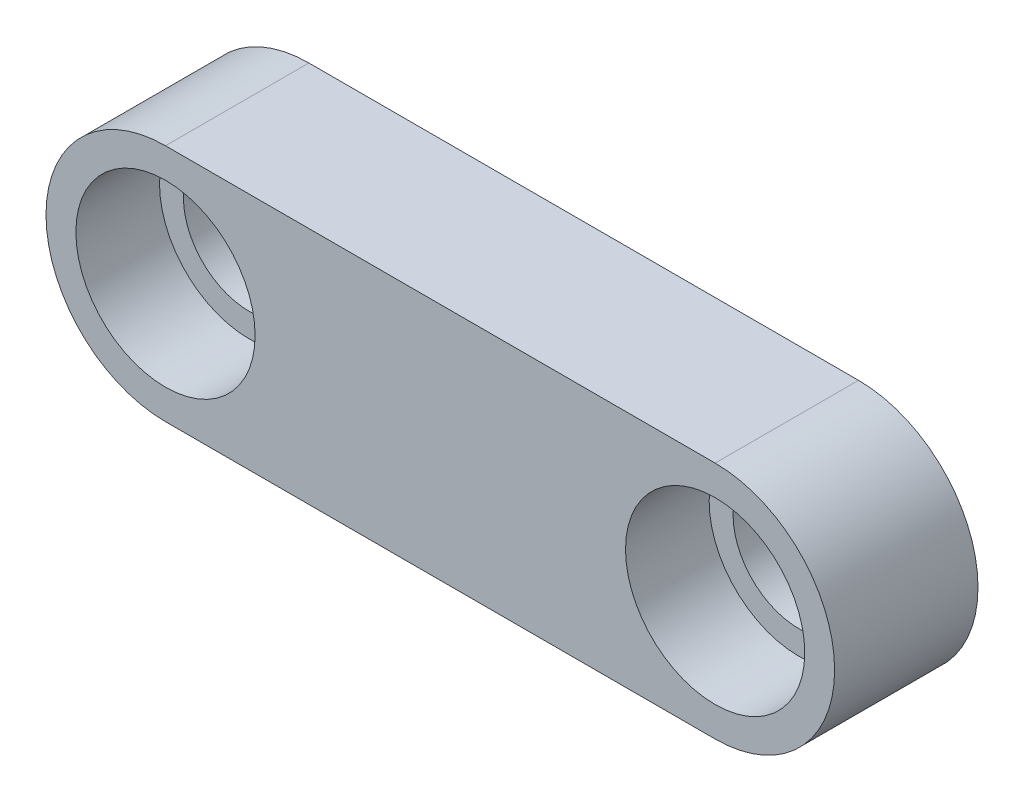
from build123d import *

# Parameters (mm, degrees)
EXTRUDE_1_DEPTH = 6


with BuildPart() as part:
    # 草图1 → 凸台-拉伸1 (new body)
    with BuildSketch(Plane.XY):
        with BuildLine():
            Line((0, 5), (23, 5))
            ThreePointArc((23, 5), (28, 0), (23, -5))
            Line((23, -5), (0, -5))
            ThreePointArc((0, -5), (-5, 0), (0, 5))
        make_face()
    extrude(amount=EXTRUDE_1_DEPTH)

    # 草图2 → 切除-旋转1 (revolve, cut)
    with BuildSketch(Plane(origin=(0, 0, 0), x_dir=(1, 0, 0), z_dir=(0, 1, 0))):
        Polygon((0, -6), (-3.75, -6), (-3.75, -2.5), (-2.75, -2.5), (-2.75, 0), (0, 0), align=None)
    revolve(axis=Axis((0, 0, 0), (0, 0, 1)), mode=Mode.SUBTRACT)

    # 草图3 → 切除-旋转2 (revolve, cut)
    with BuildSketch(Plane(origin=(0, 0, 0), x_dir=(1, 0, 0), z_dir=(0, 1, 0))):
        Polygon((23, -6), (19.25, -6), (19.25, -2.5), (20.25, -2.5), (20.25, 0), (23, 0), align=None)
    revolve(axis=Axis((23, 0, 0), (0, 0, 1)), mode=Mode.SUBTRACT)


solid = part.part
